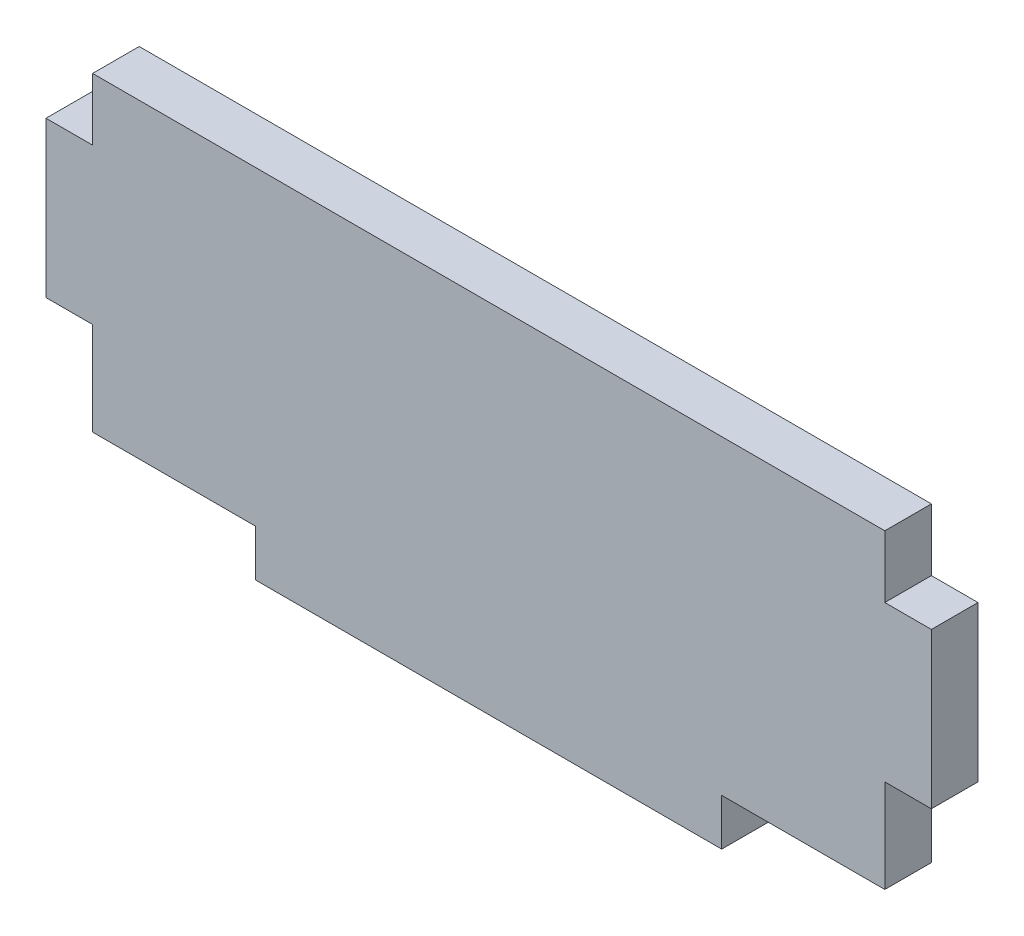
from build123d import *

# Parameters (mm, degrees)
BOSS_EXTRUDE1_DEPTH = 1.5


with BuildPart() as part:
    # Sketch1 → Boss-Extrude1 (new body, symmetric)
    with BuildSketch(Plane.XY):
        Polygon((-25.5, -4), (-25.5, -10), (-15, -10), (-15, -13), (15, -13), (15, -10), (25.5, -10), (25.5, -4), (28.5, -4), (28.5, 6), (25.5, 6), (25.5, 10), (-25.5, 10), (-25.5, 6), (-28.5, 6), (-28.5, -4), align=None)
    extrude(amount=BOSS_EXTRUDE1_DEPTH, both=True)


solid = part.part
